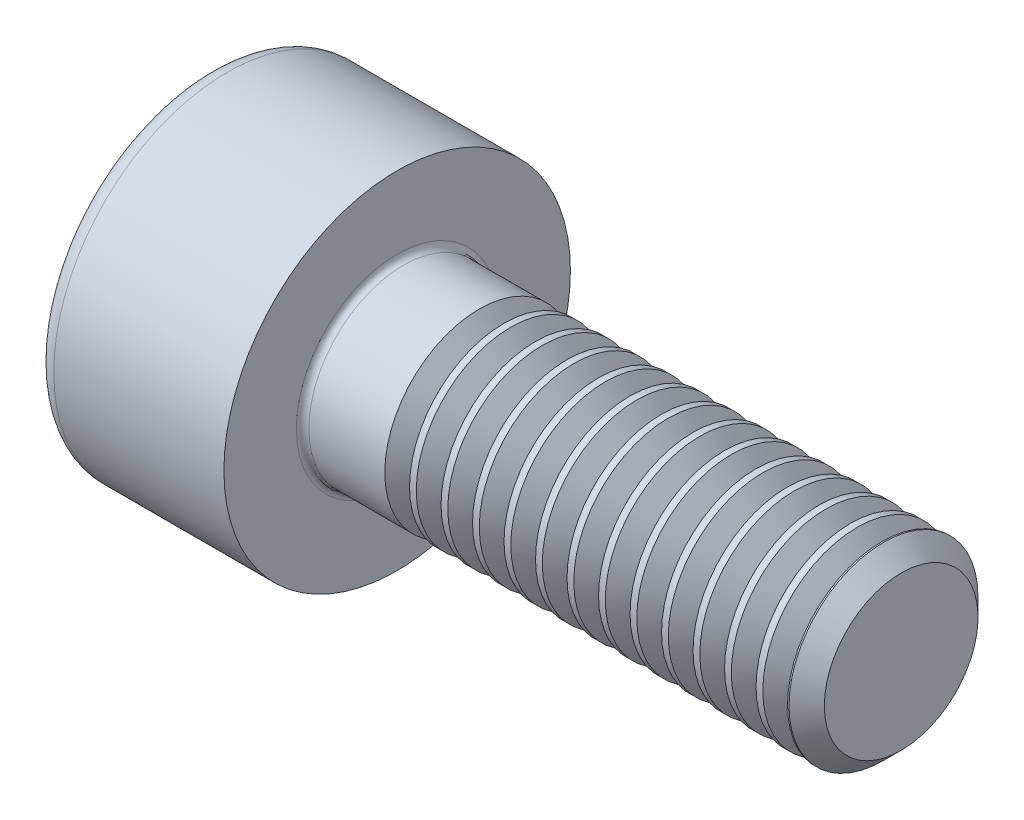
from build123d import *

# Parameters (mm, degrees)
FILLET1_R       = 0.1
FILLET2_R       = 0.3
HEX_2_DEPTH     = 1.3
THDSCHPAT_COUNT = 13
THDSCHPAT_PITCH = 0.5


with BuildPart() as part:
    # BodySke → Base-Revolve (revolve)
    with BuildSketch(Plane.XY, mode=Mode.PRIVATE) as base_revolve_sk:
        Polygon((0, 0), (0, 2.75), (3, 2.75), (3, 1.5), (10.7195, 1.5), (11, 1.2195), (11, 0), align=None)
    revolve(base_revolve_sk.sketch.rotate(Axis((-31.75, 0, 0), (1, 0, 0)), 90), axis=Axis((-31.75, 0, 0), (1, 0, 0)))  # turned: the seam where the file's is

    # Fillet1
    fillet1_edges = [part.edges().sort_by_distance(p)[0] for p in [
        (3, 0, -1.5),
    ]]
    fillet(fillet1_edges, radius=FILLET1_R)

    # Fillet2
    fillet2_edges = [part.edges().sort_by_distance(p)[0] for p in [
        (0, 0, -2.75),
    ]]
    fillet(fillet2_edges, radius=FILLET2_R)

    # Sketch2 → Hex-PreBroach (revolve, cut)
    with BuildSketch(Plane.XY, mode=Mode.PRIVATE) as hex_prebroach_sk:
        Polygon((0, 1.26), (1.3, 1.26), (2.027461339, 0), (0, 0), align=None)
    revolve(hex_prebroach_sk.sketch.rotate(Axis((0, 0, 0), (1, 0, 0)), 90), axis=Axis((0, 0, 0), (1, 0, 0)), mode=Mode.SUBTRACT)  # turned: the seam where the file's is

    # Sketch3 → Hex 2 (cut)
    with BuildSketch(Plane(origin=(0, 0, 0), x_dir=(0, 0.5, 0.866025404), z_dir=(-1, 0, 0))):
        Polygon((0.727461339, 1.26), (-0.727461339, 1.26), (-1.454922678, 0), (-0.727461339, -1.26), (0.727461339, -1.26), (1.454922678, 0), align=None)
    extrude(amount=-HEX_2_DEPTH, mode=Mode.SUBTRACT)

    # ThdSchSke → ThreadSchematic (revolve, cut)
    with BuildSketch(Plane.XY, mode=Mode.PRIVATE) as threadschematic_sk:
        Polygon((4.5, -1.2195), (4.303591786, -1.5), (4.303591786, -1.875), (4.696408214, -1.875), (4.696408214, -1.5), align=None)
    threadschematic = revolve(threadschematic_sk.sketch.rotate(Axis((-3.175, 0, 0), (1, 0, 0)), 270), axis=Axis((-3.175, 0, 0), (1, 0, 0)), mode=Mode.SUBTRACT)  # turned: the seam where the file's is

    # ThdSchPat: ThreadSchematic ×13
    with Locations(*[(i * THDSCHPAT_PITCH, 0, 0) for i in range(1, THDSCHPAT_COUNT)]):
        add(threadschematic, mode=Mode.SUBTRACT)


solid = part.part
